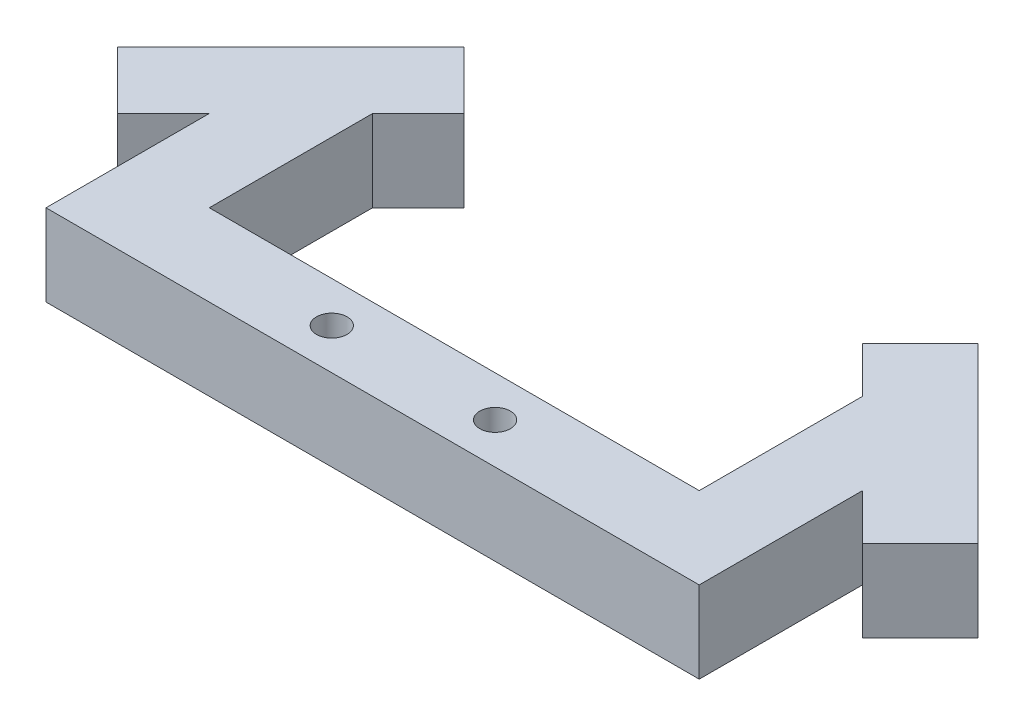
from build123d import *

# Parameters (mm, degrees)
BOSS_EXTRUDE1_DEPTH     = 25.4
SKETCH2_R               = 4.7625
CUT_EXTRUDE1_DEPTH      = 1
CUT_EXTRUDE1_DEPTH_BACK = 26.4


with BuildPart() as part:
    # Sketch1 → Boss-Extrude1 (new body)
    with BuildSketch(Plane(origin=(0, 0, 0), x_dir=(1, 0, 0), z_dir=(0, 1, 0))):
        Polygon((101.6, 0), (-101.6, 0), (-101.6, 50.8), (-76.2, 76.2), (-76.2, 25.4), (76.2, 25.4), (76.2, 76.2), (101.6, 50.8), align=None)
        Polygon((-76.2, 76.2), (-61.959231637, 90.440768363), (-79.919743879, 108.401280605), (-133.801280605, 54.519743879), (-115.840768363, 36.559231637), (-101.6, 50.8), align=None)
        Polygon((101.6, 50.8), (76.2, 76.2), (61.959231637, 90.440768363), (79.919743879, 108.401280605), (133.801280605, 54.519743879), (115.840768363, 36.559231637), align=None)
    extrude(amount=BOSS_EXTRUDE1_DEPTH)

    # Sketch2 → Cut-Extrude1 (cut, two sides)
    with BuildSketch(Plane(origin=(0, 25.4, 0), x_dir=(1, 0, 0), z_dir=(0, 1, 0))) as cut_extrude1_sk:
        with Locations((25.4, 12.7)):
            Circle(SKETCH2_R)
        with Locations((-25.4, 12.7)):
            Circle(SKETCH2_R)
    extrude(amount=CUT_EXTRUDE1_DEPTH, mode=Mode.SUBTRACT)
    extrude(cut_extrude1_sk.sketch, amount=-CUT_EXTRUDE1_DEPTH_BACK, mode=Mode.SUBTRACT)


solid = part.part
